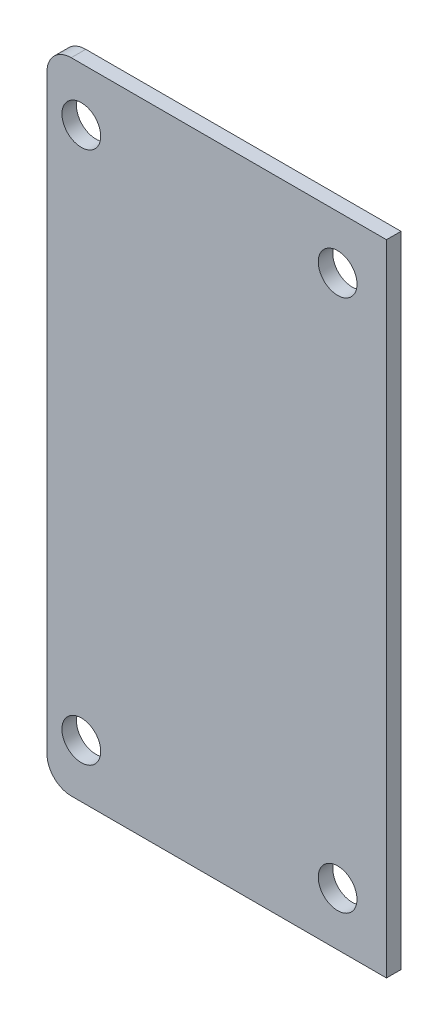
from build123d import *

# Parameters (mm, degrees)
SKETCH1_R           = 4
BOSS_EXTRUDE1_DEPTH = 3


with BuildPart() as part:
    # Sketch1 → Boss-Extrude1 (new body)
    with BuildSketch(Plane.XY):
        with BuildLine():
            Line((-35.042, 61), (-35.042, -61))
            ThreePointArc((-35.042, -61), (-33.577533906, -64.535533906), (-30.042, -66))
            Line((-30.042, -66), (35.042, -66))
            Line((35.042, -66), (35.042, 66))
            Line((35.042, 66), (-30.042, 66))
            ThreePointArc((-30.042, 66), (-33.577533906, 64.535533906), (-35.042, 61))
        make_face()
        with Locations((24.958, 55)):
            Circle(SKETCH1_R, mode=Mode.SUBTRACT)
        with Locations((-27.958, 55)):
            Circle(SKETCH1_R, mode=Mode.SUBTRACT)
        with Locations((-27.958, -55)):
            Circle(SKETCH1_R, mode=Mode.SUBTRACT)
        with Locations((24.958, -55)):
            Circle(SKETCH1_R, mode=Mode.SUBTRACT)
    extrude(amount=BOSS_EXTRUDE1_DEPTH)


solid = part.part
